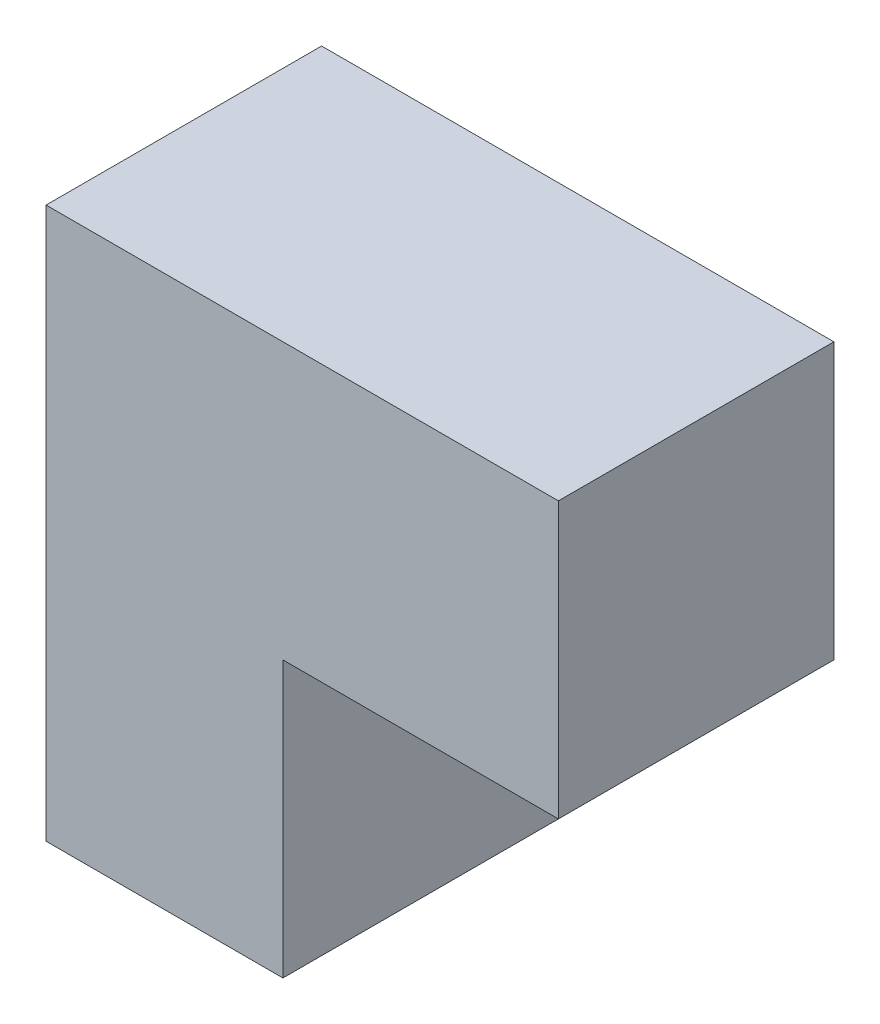
from build123d import *

# Parameters (mm, degrees)
BOSS_EXTRU_1_DEPTH = 30


with BuildPart() as part:
    # Esquisse1 → Boss.-Extru.1 (new body)
    with BuildSketch(Plane.XY):
        Polygon((0, 0), (0, 60), (55.790614525, 60), (55.790614525, 30), (25.790614525, 30), (25.790614525, 0), align=None)
    extrude(amount=BOSS_EXTRU_1_DEPTH)


solid = part.part
